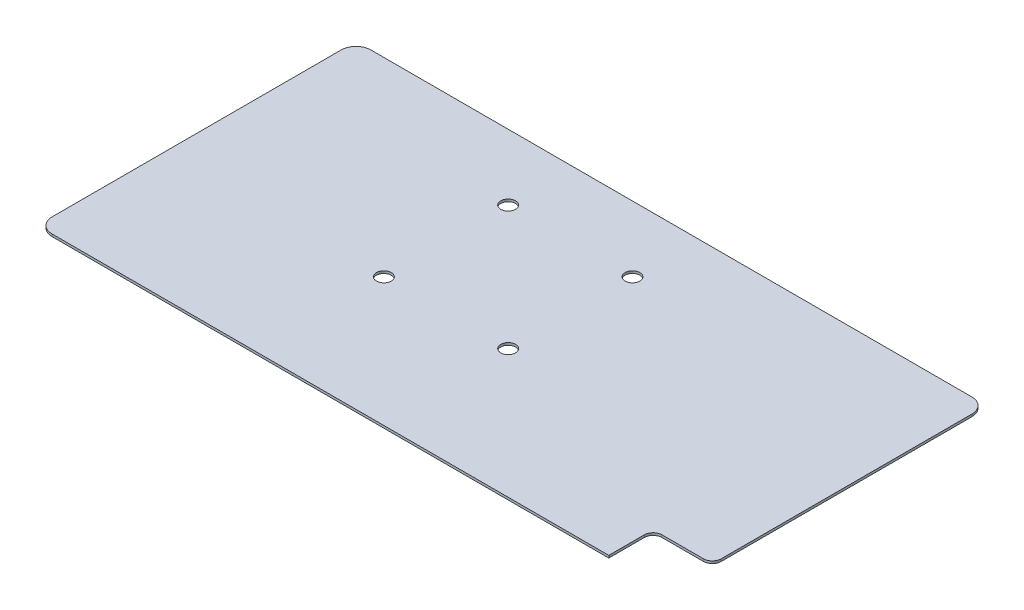
from build123d import *

# Parameters (mm, degrees)
SKETCH1_R           = 2.5
BOSS_EXTRUDE1_DEPTH = 0.8


with BuildPart() as part:
    # Sketch1 → Boss-Extrude1 (new body)
    with BuildSketch(Plane(origin=(0, 0, 0), x_dir=(1, 0, 0), z_dir=(0, 1, 0))):
        with BuildLine():
            Line((5, 0), (208.1, 0))
            ThreePointArc((208.1, 0), (211.635533906, -1.464466094), (213.1, -5))
            Line((213.1, -5), (213.1, -82.7))
            Line((213.1, -82.7), (213.1, -87.7))
            Line((213.1, -87.7), (213.1, -89.7))
            ThreePointArc((213.1, -89.7), (212.221320344, -91.821320344), (210.1, -92.7))
            Line((210.1, -92.7), (196.1, -92.7))
            ThreePointArc((196.1, -92.7), (193.978679656, -93.578679656), (193.1, -95.7))
            Line((193.1, -95.7), (193.1, -102.7))
            Line((193.1, -102.7), (193.1, -107.7))
            Line((193.1, -107.7), (188.1, -107.7))
            Line((188.1, -107.7), (5, -107.7))
            ThreePointArc((5, -107.7), (1.464466094, -106.235533906), (0, -102.7))
            Line((0, -102.7), (0, -5))
            ThreePointArc((0, -5), (1.464466094, -1.464466094), (5, 0))
        make_face()
        with Locations((73.6, -22.2)):
            Circle(SKETCH1_R, mode=Mode.SUBTRACT)
        with Locations((115.6, -22.2)):
            Circle(SKETCH1_R, mode=Mode.SUBTRACT)
        with Locations((115.6, -64.2)):
            Circle(SKETCH1_R, mode=Mode.SUBTRACT)
        with Locations((73.6, -64.2)):
            Circle(SKETCH1_R, mode=Mode.SUBTRACT)
    extrude(amount=BOSS_EXTRUDE1_DEPTH)


solid = part.part
